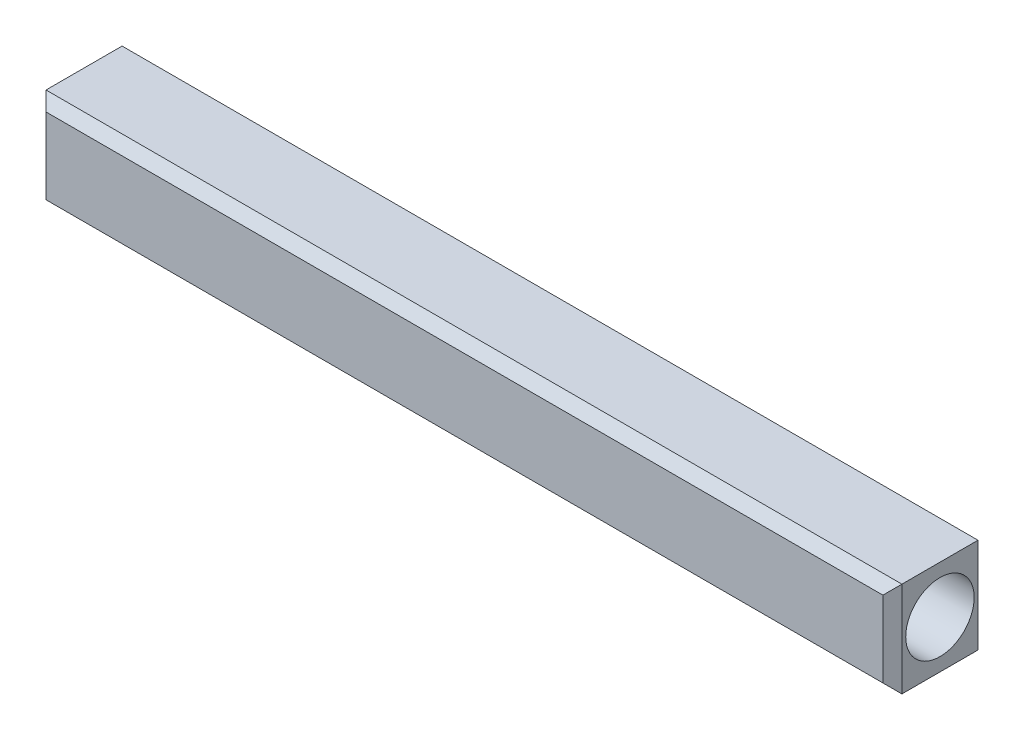
from build123d import *

# Parameters (mm, degrees)
SKETCH1_W           = 22.5
SKETCH1_H           = 5
BOSS_EXTRUDE1_DEPTH = 5
SKETCH2_R           = 1.8
CUT_EXTRUDE1_DEPTH  = 5
CHAMFER1_SIZE       = 0.5


with BuildPart() as part:
    # Sketch1 → Boss-Extrude1 (new body)
    with BuildSketch(Plane.XY):
        with Locations((-11.25, 2.5)):
            Rectangle(SKETCH1_W, SKETCH1_H)
    boss_extrude1 = extrude(amount=BOSS_EXTRUDE1_DEPTH)

    # Sketch2 → Cut-Extrude1 (cut)
    with BuildSketch(Plane.ZY.offset(22.5)):
        with Locations((2.5, 2.5)):
            Circle(SKETCH2_R)
    cut_extrude1 = extrude(amount=-CUT_EXTRUDE1_DEPTH, mode=Mode.SUBTRACT)

    # Mirror1: Boss-Extrude1, Cut-Extrude1 across plane
    add(boss_extrude1.mirror(Plane(origin=(0, 0, 0), x_dir=(0, 0, 1), z_dir=(1, 0, 0))))
    add(cut_extrude1.mirror(Plane(origin=(0, 0, 0), x_dir=(0, 0, 1), z_dir=(1, 0, 0))), mode=Mode.SUBTRACT)

    # Chamfer1
    chamfer1_edges = [part.edges().sort_by_distance(p)[0] for p in [
        (0, 5, 5),
        (-22.5, 2.5, 5),
        (22.5, 2.5, 5),
        (22.5, 2.5, 0),
        (0, 0, 5),
        (-22.5, 2.5, 0),
        (0, 5, 0),
        (0, 0, 0),
    ]]
    chamfer(chamfer1_edges, length=CHAMFER1_SIZE)


solid = part.part
